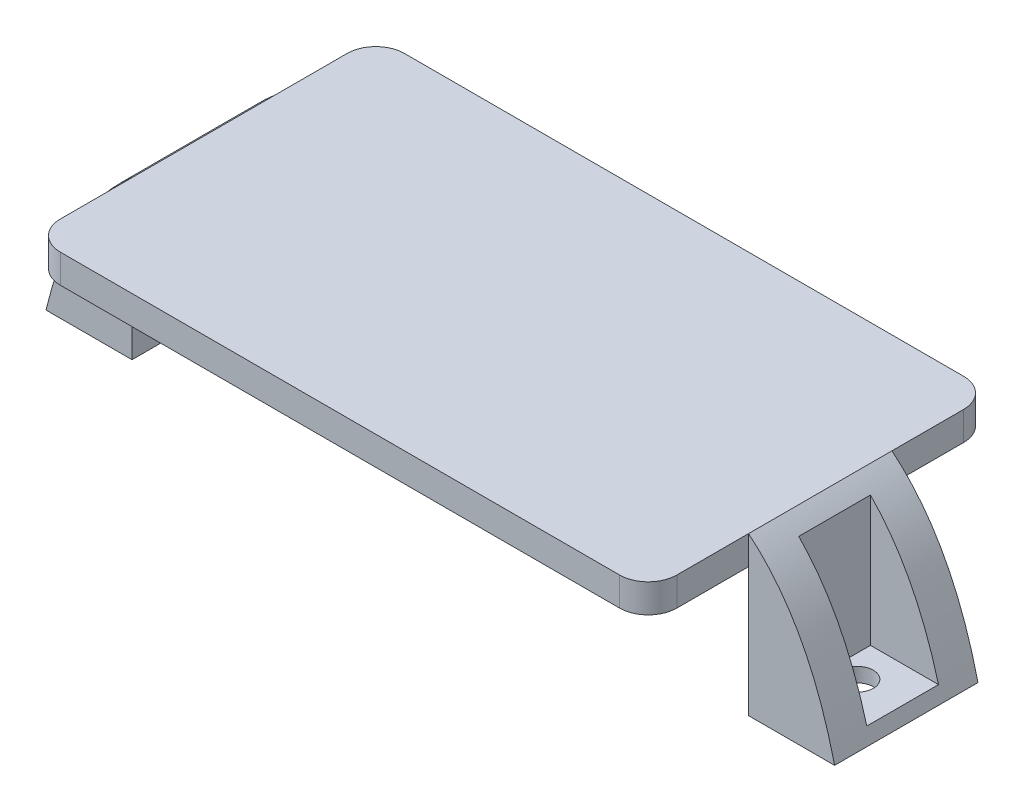
from build123d import *

# Parameters (mm, degrees)
SKETCH1_W           = 54.61
SKETCH1_H           = 30.48
BOSS_EXTRUDE1_DEPTH = 2.54
FILLET1_R           = 2.54
BOSS_EXTRUDE2_DEPTH = 6.35
SKETCH3_W           = 6.35
SKETCH3_H           = 6.35
CUT_EXTRUDE1_DEPTH  = 12.7
SKETCH4_R           = 1.397
CUT_EXTRUDE2_DEPTH  = 14.9700001


with BuildPart() as part:
    # Sketch1 → Boss-Extrude1 (new body)
    with BuildSketch(Plane(origin=(0, 0, 0), x_dir=(1, 0, 0), z_dir=(0, 1, 0))):
        Rectangle(SKETCH1_W, SKETCH1_H)
    extrude(amount=-BOSS_EXTRUDE1_DEPTH)

    # Fillet1
    fillet1_edges = [part.edges().sort_by_distance(p)[0] for p in [
        (27.305, -1.27, 15.24),
        (-27.305, -1.27, 15.24),
        (-27.305, -1.27, -15.24),
        (27.305, -1.27, -15.24),
    ]]
    fillet(fillet1_edges, radius=FILLET1_R)

    # Sketch2 → Boss-Extrude2 (add, symmetric)
    with BuildSketch(Plane.XY):
        with BuildLine():
            add(Edge.make_bspline(
                [(34.925, -13.97), (32.641767313, -4.413096047), (27.305, 0)],
                knots=[0, 0, 0, 0.368203859, 0.368203859, 0.368203859], degree=2))
            Line((27.305, 0), (27.305, -13.97))
            Line((27.305, -13.97), (34.925, -13.97))
        make_face()
    boss_extrude2 = extrude(amount=BOSS_EXTRUDE2_DEPTH, both=True)

    # Sketch3 → Cut-Extrude1 (cut)
    with BuildSketch(Plane(origin=(0, 0, 0), x_dir=(1, 0, 0), z_dir=(0, 1, 0))):
        with Locations((31.75, 0)):
            Rectangle(SKETCH3_W, SKETCH3_H)
    cut_extrude1 = extrude(amount=-CUT_EXTRUDE1_DEPTH, mode=Mode.SUBTRACT)

    # Sketch4 → Cut-Extrude2 (cut, through all)
    with BuildSketch(Plane(origin=(0, -13.97, 0), x_dir=(-1, 0, 0), z_dir=(0, -1, 0))):
        with Locations((-30.607, 0)):
            Circle(SKETCH4_R)
    cut_extrude2 = extrude(amount=-CUT_EXTRUDE2_DEPTH, mode=Mode.SUBTRACT)

    # Mirror1: Boss-Extrude2, Cut-Extrude1, Cut-Extrude2 across plane
    add(boss_extrude2.mirror(Plane(origin=(0, 0, 0), x_dir=(0, 0, 1), z_dir=(1, 0, 0))))
    add(cut_extrude1.mirror(Plane(origin=(0, 0, 0), x_dir=(0, 0, 1), z_dir=(1, 0, 0))), mode=Mode.SUBTRACT)
    add(cut_extrude2.mirror(Plane(origin=(0, 0, 0), x_dir=(0, 0, 1), z_dir=(1, 0, 0))), mode=Mode.SUBTRACT)


solid = part.part
